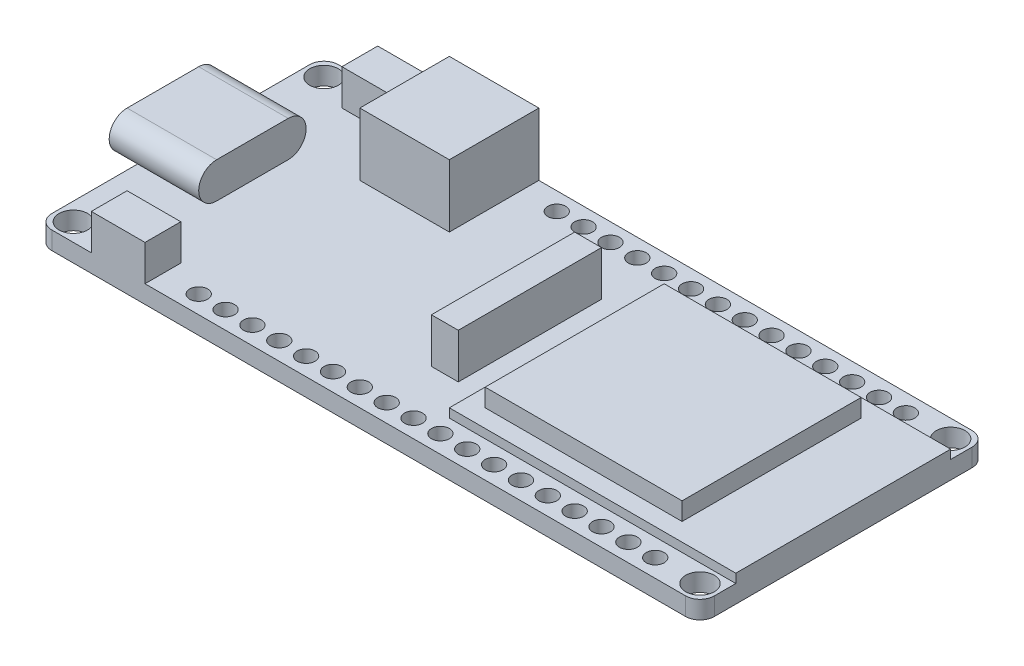
from build123d import *

# Parameters (mm, degrees)
BOSS_EXTRUDE1_DEPTH = 1.5875
SKETCH2_W           = 7.9375
SKETCH2_H           = 9.525
BOSS_EXTRUDE2_DEPTH = 3.175
CUT_EXTRUDE2_DEPTH  = 7.9375
SKETCH4_W           = 6.35
SKETCH4_H           = 0.79375
CUT_EXTRUDE3_DEPTH  = 5.3975
SKETCH5_W           = 1.5875
SKETCH5_H           = 9.525
CUT_EXTRUDE4_DEPTH  = 1.5875
SKETCH6_R           = 1.27
CUT_EXTRUDE5_DEPTH  = 1.5875
SKETCH7_W           = 25.4
SKETCH7_H           = 19.05
SKETCH7_W_2         = 17.62125
SKETCH7_H_2         = 15.875
SKETCH7_W_3         = 4.7625
SKETCH7_H_3         = 3.175
SKETCH7_W_4         = 7.9375
SKETCH7_H_4         = 7.9375
SKETCH7_W_5         = 2.38125
SKETCH7_H_5         = 12.7
BOSS_EXTRUDE3_DEPTH = 3.175
SKETCH10_W          = 7.9375
SKETCH10_H          = 7.9375
BOSS_EXTRUDE4_DEPTH = 2.38125
SKETCH11_W          = 2.38125
SKETCH11_H          = 12.7
BOSS_EXTRUDE5_DEPTH = 0.79375
SKETCH12_W          = 25.4
SKETCH12_H          = 19.05
CUT_EXTRUDE6_DEPTH  = 0.79375
SKETCH13_W          = 25.4
SKETCH13_H          = 19.05
SKETCH13_W_2        = 17.4625
SKETCH13_H_2        = 15.875
CUT_EXTRUDE7_DEPTH  = 1.5875
SKETCH14_R          = 0.79375
CUT_EXTRUDE8_DEPTH  = 1.5875


with BuildPart() as part:
    # Sketch1 → Boss-Extrude1 (new body)
    with BuildSketch(Plane(origin=(0, 0, 0), x_dir=(1, 0, 0), z_dir=(0, 1, 0))):
        Polygon((1.5875, 7.9375), (1.5875, 0), (60.325, 0), (60.325, 25.4), (1.5875, 25.4), (1.5875, 17.4625), (0, 17.4625), (0, 7.9375), align=None)
    extrude(amount=BOSS_EXTRUDE1_DEPTH)

    # Sketch2 → Boss-Extrude2 (add)
    with BuildSketch(Plane(origin=(0, 1.5875, 0), x_dir=(1, 0, 0), z_dir=(0, 1, 0))):
        with Locations((3.96875, 12.7)):
            Rectangle(SKETCH2_W, SKETCH2_H)
    extrude(amount=BOSS_EXTRUDE2_DEPTH)

    # Sketch3 → Cut-Extrude2 (cut)
    with BuildSketch(Plane.ZY):
        with BuildLine():
            Line((-15.875, 4.7625), (-17.4625, 4.7625))
            Line((-17.4625, 4.7625), (-17.4625, 3.175))
            ThreePointArc((-17.4625, 3.175), (-16.997532015, 4.297532015), (-15.875, 4.7625))
        make_face()
        with BuildLine():
            ThreePointArc((-15.875, 1.5875), (-16.997532015, 2.052467985), (-17.4625, 3.175))
            Line((-17.4625, 3.175), (-17.4625, 1.5875))
            Line((-17.4625, 1.5875), (-15.875, 1.5875))
        make_face()
        with BuildLine():
            Line((-7.9375, 4.7625), (-9.525, 4.7625))
            ThreePointArc((-9.525, 4.7625), (-8.402467985, 4.297532015), (-7.9375, 3.175))
            Line((-7.9375, 3.175), (-7.9375, 4.7625))
        make_face()
        with BuildLine():
            Line((-7.9375, 1.5875), (-7.9375, 3.175))
            ThreePointArc((-7.9375, 3.175), (-8.402467985, 2.052467985), (-9.525, 1.5875))
            Line((-9.525, 1.5875), (-7.9375, 1.5875))
        make_face()
    extrude(amount=-CUT_EXTRUDE2_DEPTH, mode=Mode.SUBTRACT)

    # Sketch4 → Cut-Extrude3 (cut)
    with BuildSketch(Plane.ZY):
        with BuildLine():
            Line((-15.875, 1.984375), (-9.525, 1.984375))
            ThreePointArc((-9.525, 1.984375), (-8.334375, 3.175), (-9.525, 4.365625))
            Line((-9.525, 4.365625), (-15.875, 4.365625))
            ThreePointArc((-15.875, 4.365625), (-17.065625, 3.175), (-15.875, 1.984375))
        make_face()
        with Locations((-12.7, 3.175)):
            Rectangle(SKETCH4_W, SKETCH4_H, mode=Mode.SUBTRACT)
    extrude(amount=-CUT_EXTRUDE3_DEPTH, mode=Mode.SUBTRACT)

    # Sketch5 → Cut-Extrude4 (cut)
    with BuildSketch(Plane.XZ):
        with Locations((0.79375, -12.7)):
            Rectangle(SKETCH5_W, SKETCH5_H)
    extrude(amount=-CUT_EXTRUDE4_DEPTH, mode=Mode.SUBTRACT)

    # Sketch6 → Cut-Extrude5 (cut)
    with BuildSketch(Plane(origin=(0, 1.5875, 0), x_dir=(1, 0, 0), z_dir=(0, 1, 0))):
        with BuildLine():
            ThreePointArc((1.5875, 24.13), (1.959474388, 25.028025612), (2.8575, 25.4))
            Line((2.8575, 25.4), (1.5875, 25.4))
            Line((1.5875, 25.4), (1.5875, 24.13))
        make_face()
        with BuildLine():
            ThreePointArc((2.8575, 0), (1.959474388, 0.371974388), (1.5875, 1.27))
            Line((1.5875, 1.27), (1.5875, 0))
            Line((1.5875, 0), (2.8575, 0))
        make_face()
        with BuildLine():
            Line((60.325, 0), (60.325, 1.27))
            ThreePointArc((60.325, 1.27), (59.953025612, 0.371974388), (59.055, 0))
            Line((59.055, 0), (60.325, 0))
        make_face()
        with BuildLine():
            Line((60.325, 25.4), (59.055, 25.4))
            ThreePointArc((59.055, 25.4), (59.953025612, 25.028025612), (60.325, 24.13))
            Line((60.325, 24.13), (60.325, 25.4))
        make_face()
        with Locations(Location((3.175, 23.8125, 0), (0, 0, 270))):
            Circle(SKETCH6_R)
        with Locations(Location((3.175, 1.5875, 0), (0, 0, 270))):
            Circle(SKETCH6_R)
        with Locations(Location((58.7375, 1.5875, 0), (0, 0, 270))):
            Circle(SKETCH6_R)
        with Locations(Location((58.7375, 23.8125, 0), (0, 0, 270))):
            Circle(SKETCH6_R)
    extrude(amount=-CUT_EXTRUDE5_DEPTH, mode=Mode.SUBTRACT)

    # Sketch7 → Boss-Extrude3 (add)
    with BuildSketch(Plane(origin=(0, 1.5875, 0), x_dir=(1, 0, 0), z_dir=(0, 1, 0))):
        with Locations((47.625, 12.7)):
            Rectangle(SKETCH7_W, SKETCH7_H)
        with Locations((45.323125, 12.7)):
            Rectangle(SKETCH7_W_2, SKETCH7_H_2, mode=Mode.SUBTRACT)
        with Locations((45.323125, 12.7)):
            Rectangle(SKETCH7_W_2, SKETCH7_H_2)
        with Locations((8.73125, 23.8125)):
            Rectangle(SKETCH7_W_3, SKETCH7_H_3)
        with Locations((8.73125, 1.5875)):
            Rectangle(SKETCH7_W_3, SKETCH7_H_3)
        with Locations((16.66875, 21.43125)):
            Rectangle(SKETCH7_W_4, SKETCH7_H_4)
        with Locations((31.353125, 12.7)):
            Rectangle(SKETCH7_W_5, SKETCH7_H_5)
    extrude(amount=BOSS_EXTRUDE3_DEPTH)

    # Sketch10 → Boss-Extrude4 (add)
    with BuildSketch(Plane(origin=(0, 4.7625, 0), x_dir=(1, 0, 0), z_dir=(0, 1, 0))):
        with Locations((16.66875, 21.43125)):
            Rectangle(SKETCH10_W, SKETCH10_H)
    extrude(amount=BOSS_EXTRUDE4_DEPTH)

    # Sketch11 → Boss-Extrude5 (add)
    with BuildSketch(Plane(origin=(0, 4.7625, 0), x_dir=(1, 0, 0), z_dir=(0, 1, 0))):
        with Locations((31.353125, 12.7)):
            Rectangle(SKETCH11_W, SKETCH11_H)
    extrude(amount=BOSS_EXTRUDE5_DEPTH)

    # Sketch12 → Cut-Extrude6 (cut)
    with BuildSketch(Plane(origin=(0, 4.7625, 0), x_dir=(1, 0, 0), z_dir=(0, 1, 0))):
        with Locations((47.625, 12.7)):
            Rectangle(SKETCH12_W, SKETCH12_H)
    extrude(amount=-CUT_EXTRUDE6_DEPTH, mode=Mode.SUBTRACT)

    # Sketch13 → Cut-Extrude7 (cut)
    with BuildSketch(Plane(origin=(0, 3.96875, 0), x_dir=(1, 0, 0), z_dir=(0, 1, 0))):
        with Locations((47.625, 12.7)):
            Rectangle(SKETCH13_W, SKETCH13_H)
        with Locations((45.24375, 12.7)):
            Rectangle(SKETCH13_W_2, SKETCH13_H_2, mode=Mode.SUBTRACT)
    extrude(amount=-CUT_EXTRUDE7_DEPTH, mode=Mode.SUBTRACT)

    # Sketch14 → Cut-Extrude8 (cut)
    with BuildSketch(Plane(origin=(0, 1.5875, 0), x_dir=(1, 0, 0), z_dir=(0, 1, 0))):
        with Locations(Location((23.8125, 23.8125, 0), (0, 0, 270))):
            Circle(SKETCH14_R)
        with Locations(Location((26.19375, 23.8125, 0), (0, 0, 270))):
            Circle(SKETCH14_R)
        with Locations(Location((28.575, 23.8125, 0), (0, 0, 270))):
            Circle(SKETCH14_R)
        with Locations(Location((30.95625, 23.8125, 0), (0, 0, 270))):
            Circle(SKETCH14_R)
        with Locations(Location((38.1, 23.8125, 0), (0, 0, 270))):
            Circle(SKETCH14_R)
        with Locations(Location((42.8625, 23.8125, 0), (0, 0, 270))):
            Circle(SKETCH14_R)
        with Locations(Location((33.3375, 23.8125, 0), (0, 0, 270))):
            Circle(SKETCH14_R)
        with Locations(Location((35.71875, 23.8125, 0), (0, 0, 270))):
            Circle(SKETCH14_R)
        with Locations(Location((40.48125, 23.8125, 0), (0, 0, 270))):
            Circle(SKETCH14_R)
        with Locations(Location((45.24375, 23.8125, 0), (0, 0, 270))):
            Circle(SKETCH14_R)
        with Locations(Location((47.625, 23.8125, 0), (0, 0, 270))):
            Circle(SKETCH14_R)
        with Locations(Location((50.00625, 23.8125, 0), (0, 0, 270))):
            Circle(SKETCH14_R)
        with Locations(Location((52.3875, 23.8125, 0), (0, 0, 270))):
            Circle(SKETCH14_R)
        with Locations(Location((54.76875, 23.8125, 0), (0, 0, 270))):
            Circle(SKETCH14_R)
        with Locations(Location((14.2875, 1.5875, 0), (0, 0, 270))):
            Circle(SKETCH14_R)
        with Locations(Location((16.66875, 1.5875, 0), (0, 0, 270))):
            Circle(SKETCH14_R)
        with Locations(Location((19.05, 1.5875, 0), (0, 0, 270))):
            Circle(SKETCH14_R)
        with Locations(Location((21.43125, 1.5875, 0), (0, 0, 270))):
            Circle(SKETCH14_R)
        with Locations(Location((23.8125, 1.5875, 0), (0, 0, 270))):
            Circle(SKETCH14_R)
        with Locations(Location((26.19375, 1.5875, 0), (0, 0, 270))):
            Circle(SKETCH14_R)
        with Locations(Location((28.575, 1.5875, 0), (0, 0, 270))):
            Circle(SKETCH14_R)
        with Locations(Location((30.95625, 1.5875, 0), (0, 0, 270))):
            Circle(SKETCH14_R)
        with Locations(Location((33.3375, 1.5875, 0), (0, 0, 270))):
            Circle(SKETCH14_R)
        with Locations(Location((35.71875, 1.5875, 0), (0, 0, 270))):
            Circle(SKETCH14_R)
        with Locations(Location((38.1, 1.5875, 0), (0, 0, 270))):
            Circle(SKETCH14_R)
        with Locations(Location((40.48125, 1.5875, 0), (0, 0, 270))):
            Circle(SKETCH14_R)
        with Locations(Location((42.8625, 1.5875, 0), (0, 0, 270))):
            Circle(SKETCH14_R)
        with Locations(Location((45.24375, 1.5875, 0), (0, 0, 270))):
            Circle(SKETCH14_R)
        with Locations(Location((47.625, 1.5875, 0), (0, 0, 270))):
            Circle(SKETCH14_R)
        with Locations(Location((50.00625, 1.5875, 0), (0, 0, 270))):
            Circle(SKETCH14_R)
        with Locations(Location((52.3875, 1.5875, 0), (0, 0, 270))):
            Circle(SKETCH14_R)
        with Locations(Location((54.76875, 1.5875, 0), (0, 0, 270))):
            Circle(SKETCH14_R)
    extrude(amount=-CUT_EXTRUDE8_DEPTH, mode=Mode.SUBTRACT)


solid = part.part
